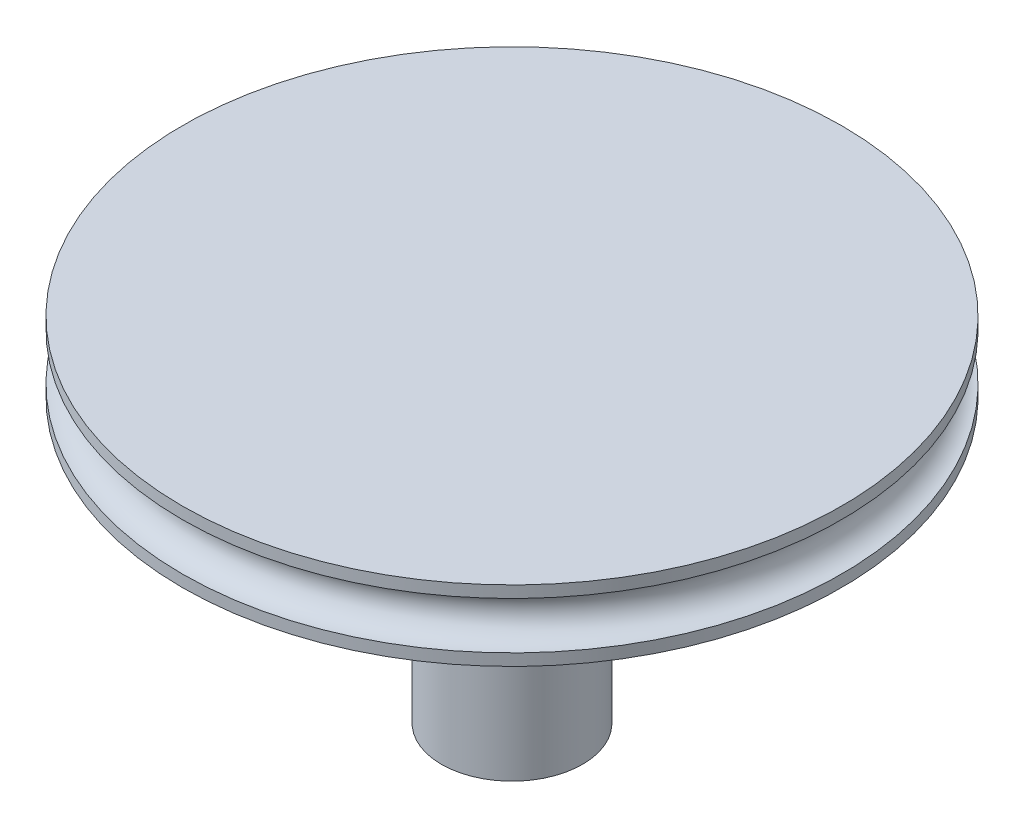
from build123d import *


with BuildPart() as part:
    # Sketch1 → Revolve1 (revolve)
    with BuildSketch(Plane.XY):
        with BuildLine():
            Line((3, 0), (14, 0))
            Line((14, 0), (14, 0.5))
            ThreePointArc((14, 0.5), (13, 1.5), (14, 2.5))
            Line((14, 2.5), (14, 3))
            Line((14, 3), (0, 3))
            Line((0, 3), (0, -12))
            Line((0, -12), (3, -12))
            Line((3, -12), (3, 0))
        make_face()
    revolve(axis=Axis((0, 3.6, 0), (0, -1, 0)))


solid = part.part
